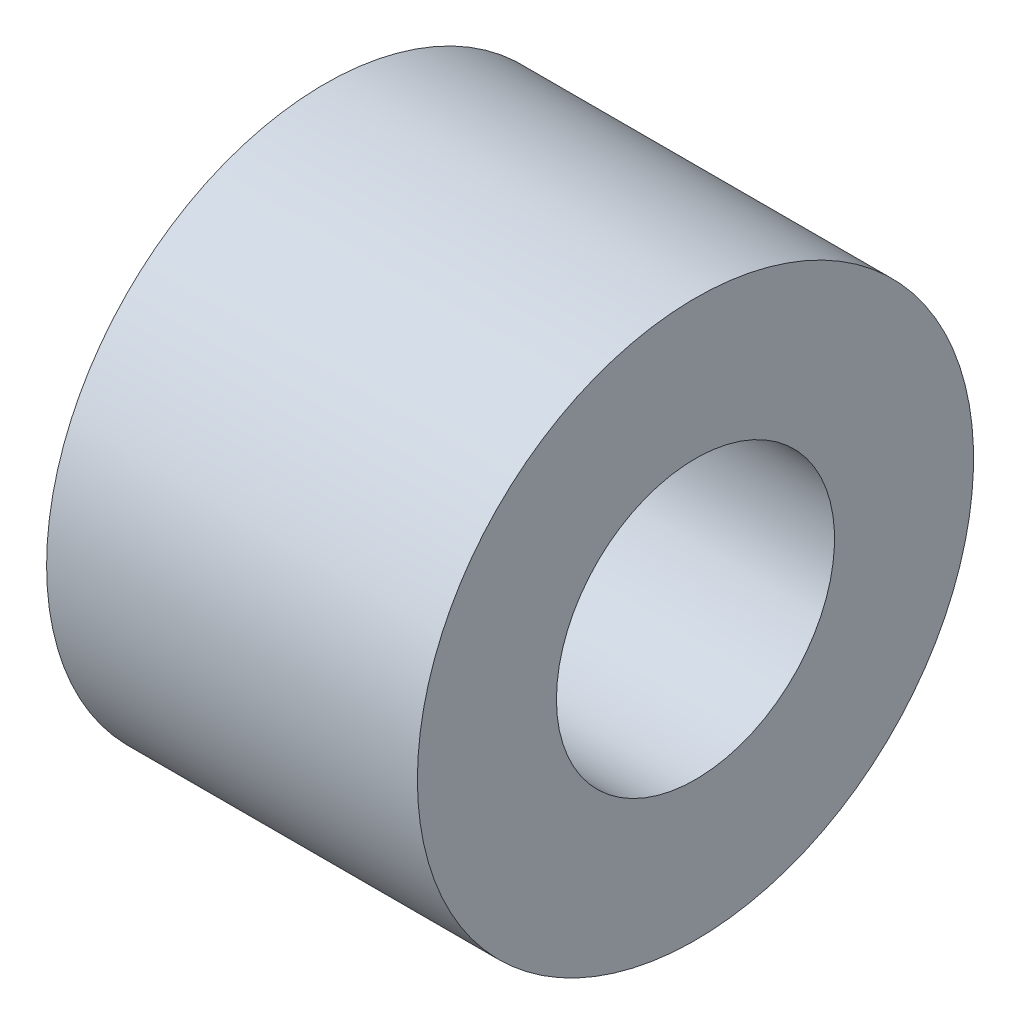
from build123d import *

# Parameters (mm, degrees)
ESQUISSE1_W = 10
ESQUISSE1_H = 3.75


with BuildPart() as part:
    # Esquisse1 → Révolution1 (revolve)
    with BuildSketch(Plane.XY, mode=Mode.PRIVATE) as r_volution1_sk:
        with Locations((-18.907423, 5.625)):
            Rectangle(ESQUISSE1_W, ESQUISSE1_H)
    revolve(r_volution1_sk.sketch.rotate(Axis((-47.526804124, 0, 0), (1, 0, 0)), 90), axis=Axis((-47.526804124, 0, 0), (1, 0, 0)))  # turned: the seam where the file's is


solid = part.part
